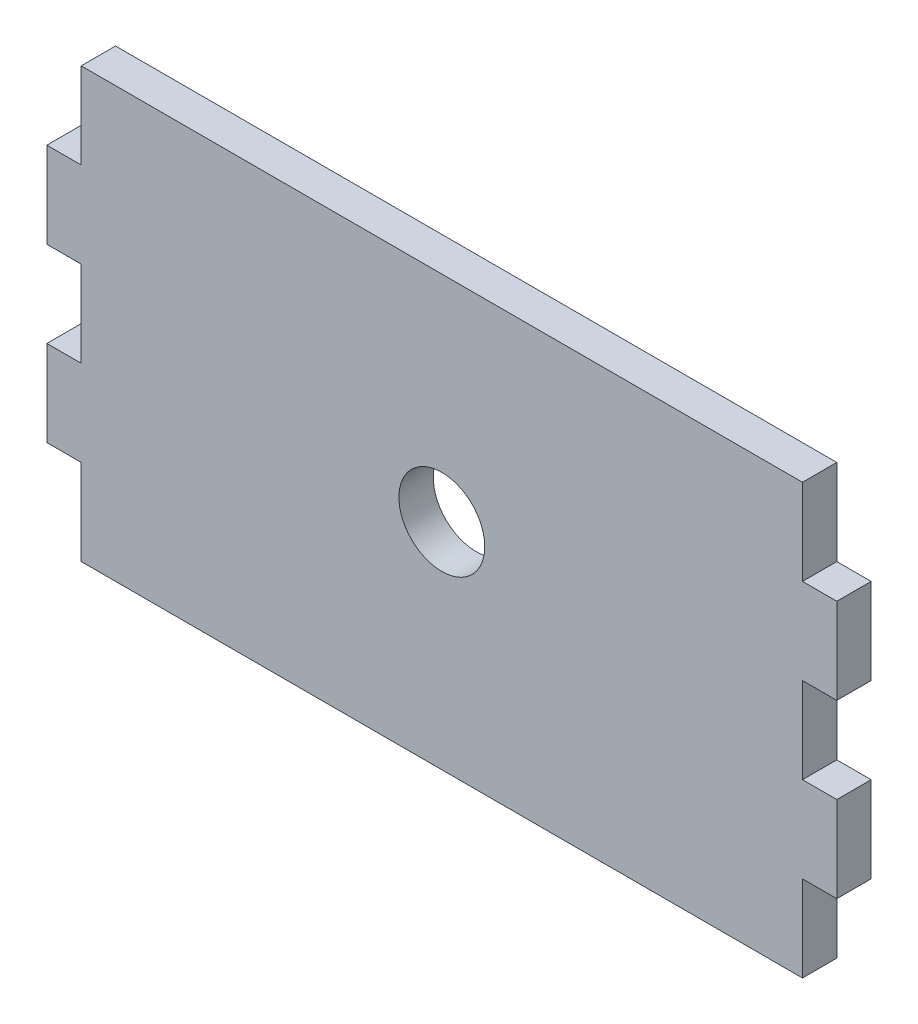
from build123d import *

# Parameters (mm, degrees)
SKETCH1_R           = 5
BOSS_EXTRUDE1_DEPTH = 4


with BuildPart() as part:
    # Sketch1 → Boss-Extrude1 (new body)
    with BuildSketch(Plane.XY):
        Polygon((-46, 5), (-46, 15), (-42, 15), (-42, 25), (42, 25), (42, 15), (46, 15), (46, 5), (42, 5), (42, -5), (46, -5), (46, -15), (42, -15), (42, -25), (-42, -25), (-42, -15), (-46, -15), (-46, -5), (-42, -5), (-42, 5), align=None)
        Circle(SKETCH1_R, mode=Mode.SUBTRACT)
    extrude(amount=BOSS_EXTRUDE1_DEPTH)


solid = part.part
